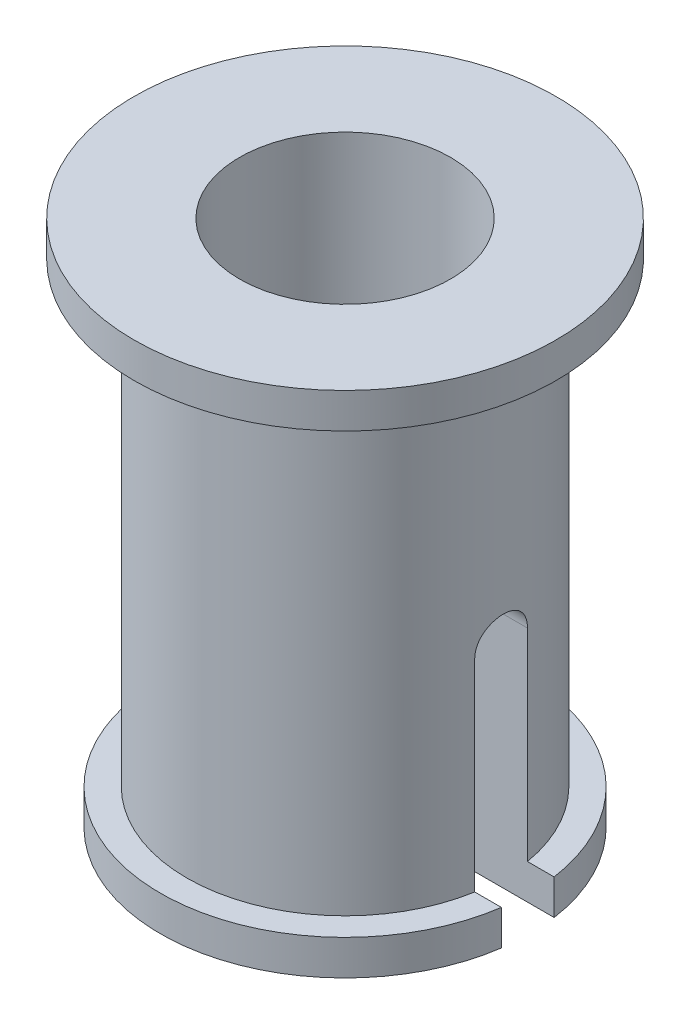
from build123d import *

# Parameters (mm, degrees)
SKETCH1_R               = 1.5
SKETCH1_R_2             = 1
BOSS_EXTRUDE1_DEPTH     = 5
SKETCH2_R               = 2
SKETCH2_R_2             = 1
BOSS_EXTRUDE2_DEPTH     = 0.333333333
SKETCH3_R               = 1.75
SKETCH3_R_2             = 1
BOSS_EXTRUDE4_DEPTH     = 0.333333333
SKETCH4_R               = 0.25
SKETCH4_W               = 0.5
SKETCH4_H               = 2.25
CUT_EXTRUDE1_DEPTH      = 3
CUT_EXTRUDE1_DEPTH_BACK = 3


with BuildPart() as part:
    # Sketch1 → Boss-Extrude1 (new body)
    with BuildSketch(Plane(origin=(0, 0, 0), x_dir=(1, 0, 0), z_dir=(0, 1, 0))):
        Circle(SKETCH1_R)
        Circle(SKETCH1_R_2, mode=Mode.SUBTRACT)
    extrude(amount=BOSS_EXTRUDE1_DEPTH)

    # Sketch2 → Boss-Extrude2 (add)
    with BuildSketch(Plane(origin=(0, 5, 0), x_dir=(1, 0, 0), z_dir=(0, 1, 0))):
        Circle(SKETCH2_R)
        Circle(SKETCH2_R_2, mode=Mode.SUBTRACT)
    extrude(amount=-BOSS_EXTRUDE2_DEPTH)

    # Sketch3 → Boss-Extrude4 (add)
    with BuildSketch(Plane(origin=(0, 0, 0), x_dir=(-1, 0, 0), z_dir=(0, -1, 0))):
        Circle(SKETCH3_R)
        Circle(SKETCH3_R_2, mode=Mode.SUBTRACT)
    extrude(amount=-BOSS_EXTRUDE4_DEPTH)

    # Sketch4 → Cut-Extrude1 (cut, two sides)
    with BuildSketch(Plane(origin=(0, 0, 0), x_dir=(0, 0, -1), z_dir=(1, 0, 0))) as cut_extrude1_sk:
        with Locations((0, 2.25)):
            Circle(SKETCH4_R)
        with Locations((0, 1.125)):
            Rectangle(SKETCH4_W, SKETCH4_H)
    extrude(amount=CUT_EXTRUDE1_DEPTH, mode=Mode.SUBTRACT)
    extrude(cut_extrude1_sk.sketch, amount=-CUT_EXTRUDE1_DEPTH_BACK, mode=Mode.SUBTRACT)


solid = part.part
